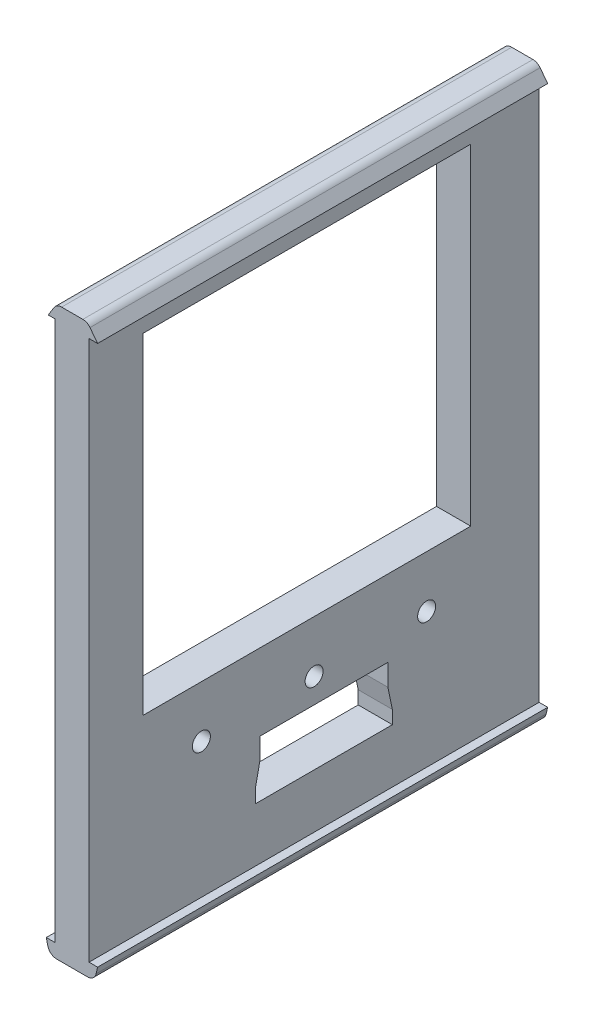
from build123d import *

# Parameters (mm, degrees)
RESSALTO_EXTRUS_O1_DEPTH   = 160
ESBO_O2_W                  = 7.6
ESBO_O2_H                  = 120
CORTE_EXTRUS_O1_DEPTH      = 30
CORTE_EXTRUS_O2_DEPTH      = 30
F_3DSKETCH3_R              = 2
CORTE_EXTRUS_O3_DEPTH      = 70
ESBO_O3_W                  = 45.015344868
ESBO_O3_H                  = 129.478543367
ESBO_O3_W_2                = 37.192593828
CORTE_EXTRUS_O4_DEPTH      = 41
CORTE_EXTRUS_O4_DEPTH_BACK = 22
ESBO_O4_W                  = 72.8
ESBO_O4_H                  = 73.5
CORTE_EXTRUS_O5_DEPTH      = 34
CORTE_EXTRUS_O5_DEPTH_BACK = 36


with BuildPart() as part:
    # Esboço1 → Ressalto-extrusão1 (new body)
    with BuildSketch(Plane.XY):
        with BuildLine():
            Line((-3.8, 21.821375341), (-3.8, -98.178624659))
            Line((-3.8, -98.178624659), (-5.7, -98.178624659))
            Line((-5.7, -98.178624659), (-5.360626179, -99.63308389))
            ThreePointArc((-5.360626179, -99.63308389), (-4.656141559, -100.745296045), (-3.41294376, -101.178624659))
            Line((-3.41294376, -101.178624659), (3.41294376, -101.178624659))
            ThreePointArc((3.41294376, -101.178624659), (4.656141559, -100.745296045), (5.360626179, -99.63308389))
            Line((5.360626179, -99.63308389), (5.7, -98.178624659))
            Line((5.7, -98.178624659), (3.8, -98.178624659))
            Line((3.8, -98.178624659), (3.8, 21.821375341))
            Line((3.8, 21.821375341), (5.7, 21.821375341))
            Line((5.7, 21.821375341), (4.013268169, 24.033911877))
            ThreePointArc((4.013268169, 24.033911877), (3.310139149, 24.613730366), (2.422747768, 24.821375341))
            Line((2.422747768, 24.821375341), (-2.297792791, 24.821375341))
            ThreePointArc((-2.297792791, 24.821375341), (-3.27177376, 24.568189891), (-3.999156919, 23.872736414))
            Line((-3.999156919, 23.872736414), (-5.266799243, 21.821375341))
            Line((-5.266799243, 21.821375341), (-3.8, 21.821375341))
        make_face()
    extrude(amount=RESSALTO_EXTRUS_O1_DEPTH)

    # Esboço2 → Corte-extrusão1 (cut)
    with BuildSketch(Plane.XY):
        with Locations((0, -38.178624659)):
            Rectangle(ESBO_O2_W, ESBO_O2_H)
    extrude(amount=CORTE_EXTRUS_O1_DEPTH, mode=Mode.SUBTRACT)

    # 3DSketch2 → Corte-extrusão2 (cut)
    with BuildSketch(Plane(origin=(-3.8, 21.821375341, 160), x_dir=(0.0632066956560733, -0.9980004577274705, 0), z_dir=(0, 0, -1))):
        Polygon((0, 0), (0.480370887, -7.584803479), (120.240425814, 0), (119.760054927, 7.584803479), align=None)
    extrude(amount=CORTE_EXTRUS_O2_DEPTH, mode=Mode.SUBTRACT)

    # 3DSketch3 → Corte-extrusão3 (cut)
    with BuildSketch(Plane(origin=(3.8, -38.178624659, 80), x_dir=(0, 0.7676852805184269, 0.6408270516101394), z_dir=(1, 0, 0))):
        with Locations(Location((0, 0, 0), (0, 0, 140.146481665))):
            Circle(F_3DSKETCH3_R)
        with Locations(Location((23.030558416, -19.224811548, 0), (0, 0, 140.146481665))):
            Circle(F_3DSKETCH3_R)
        with Locations(Location((-23.030558416, 19.224811548, 0), (0, 0, 140.146481665))):
            Circle(F_3DSKETCH3_R)
        with Locations(Location((-39.051234706, 0.032679535, 0), (0, 0, 140.146481665))):
            Circle(F_3DSKETCH3_R)
        with Locations(Location((-16.02067629, -19.192132013, 0), (0, 0, 140.146481665))):
            Circle(F_3DSKETCH3_R)
        with Locations(Location((7.009882125, -38.416943561, 0), (0, 0, 140.146481665))):
            Circle(F_3DSKETCH3_R)
        with Locations(Location((-6.982602808, 38.449623097, 0), (0, 0, 140.146481665))):
            Circle(F_3DSKETCH3_R)
        with Locations(Location((16.047955607, 19.224811548, 0), (0, 0, 140.146481665))):
            Circle(F_3DSKETCH3_R)
        with Locations(Location((39.078514023, 0, 0), (0, 0, 140.146481665))):
            Circle(F_3DSKETCH3_R)
    extrude(amount=-CORTE_EXTRUS_O3_DEPTH, mode=Mode.SUBTRACT)

    # Esboço3 → Corte-extrusão4 (cut, two sides)
    with BuildSketch(Plane(origin=(0, 0, 0), x_dir=(0, 0, -1), z_dir=(1, 0, 0))) as corte_extrus_o4_sk:
        with Locations((-7.492327566, -39.917896343)):
            Rectangle(ESBO_O3_W, ESBO_O3_H)
        with Locations((-148.596296914, -39.917896343)):
            Rectangle(ESBO_O3_W_2, ESBO_O3_H)
    extrude(amount=CORTE_EXTRUS_O4_DEPTH, mode=Mode.SUBTRACT)
    extrude(corte_extrus_o4_sk.sketch, amount=-CORTE_EXTRUS_O4_DEPTH_BACK, mode=Mode.SUBTRACT)

    # Esboço4 → Corte-extrusão5 (cut, two sides)
    with BuildSketch(Plane(origin=(0, 0, 0), x_dir=(0, 0, -1), z_dir=(1, 0, 0))) as corte_extrus_o5_sk:
        with Locations((-81.6, -19.928624659)):
            Rectangle(ESBO_O4_W, ESBO_O4_H)
        Polygon((-93.057510279, -86.178624659), (-62.607510279, -86.178624659), (-62.607510279, -83.253419483), (-63.607510279, -78.466022071), (-63.607510279, -73.678624659), (-92.057510279, -73.678624659), (-92.057510279, -78.466022071), (-93.057510279, -83.253419483), align=None)
    extrude(amount=CORTE_EXTRUS_O5_DEPTH, mode=Mode.SUBTRACT)
    extrude(corte_extrus_o5_sk.sketch, amount=-CORTE_EXTRUS_O5_DEPTH_BACK, mode=Mode.SUBTRACT)


solid = part.part
